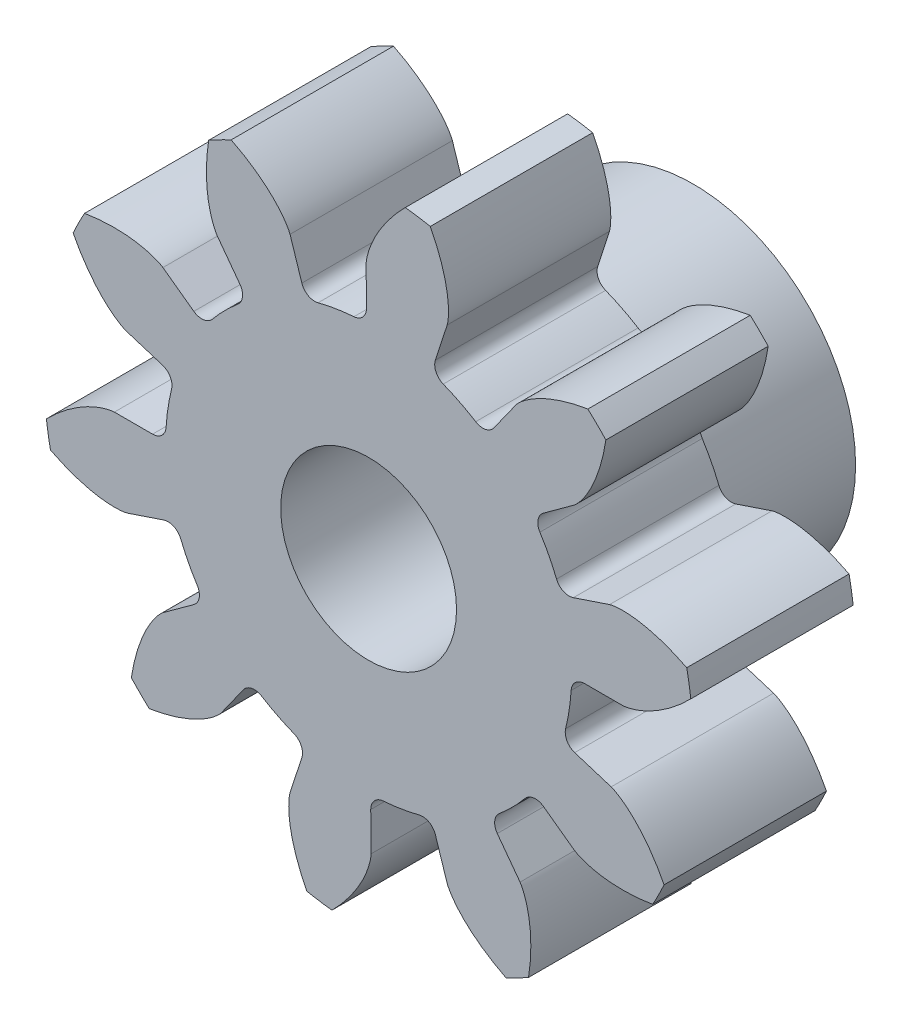
from build123d import *

# Parameters (mm, degrees)
BOSS_EXTRUDE3_DEPTH      = 3
FILLET1_R                = 0.25
CIRPATTERN8_COUNT        = 10
CIRPATTERN8_COPY_1_DEPTH = 3
CIRPATTERN8_COPY_2_DEPTH = 3
CIRPATTERN8_COPY_3_DEPTH = 3
CIRPATTERN8_COPY_4_DEPTH = 3
CIRPATTERN8_COPY_5_DEPTH = 3
CIRPATTERN8_COPY_6_DEPTH = 3
CIRPATTERN8_COPY_7_DEPTH = 3
CIRPATTERN8_COPY_8_DEPTH = 3
CIRPATTERN8_COPY_9_DEPTH = 3
FILLET1_OF_CIRPATTERN8_R = 0.25
SKETCH3_R                = 1.625
CUT_EXTRUDE2_DEPTH       = 9.944202226
SKETCH4_R                = 3
SKETCH4_R_2              = 1.625
BOSS_EXTRUDE4_DEPTH      = 3


with BuildPart() as part:
    # Sketch1 → Boss-Extrude3 (new body)
    with BuildSketch(Plane.XY):
        with BuildLine():
            Line((3.75, 0), (4.698463104, 0))
            add(Edge.make_bspline(
                [(4.698463104, 0), (4.701936693, 7.3507e-05), (4.711671667, 0.000507155), (4.730035453, 0.002224847), (4.759876783, 0.006298442), (4.79766874, 0.013349079), (4.846157716, 0.02458424), (4.902733795, 0.040529055), (4.964229103, 0.060864675), (5.030289125, 0.085989187), (5.095362708, 0.113680418), (5.159425932, 0.143715794), (5.222425493, 0.175792819), (5.297691656, 0.217156604), (5.386434991, 0.270222415), (5.487756287, 0.337177562), (5.599668365, 0.418847249), (5.710232197, 0.508010197), (5.812558898, 0.597496992), (5.886666635, 0.668145407), (5.93326076, 0.714427159), (5.954667219, 0.736164592)],
                knots=[0, 0, 0, 0, 0, 0.005376748, 0.015083688, 0.02853182, 0.046610139, 0.064854849, 0.092110525, 0.119476175, 0.146842495, 0.174208853, 0.201574955, 0.228941013, 0.256307345, 0.307035032, 0.361767351, 0.41649966, 0.471231936, 0.525964281, 0.573449371, 0.573449371, 0.573449371, 0.573449371, 0.573449371], degree=4))
            ThreePointArc((5.954667219, 0.736164592), (5.939189457, 0.852073114), (5.921455736, 0.967657983))
            Line((5.921455736, 0.967657983), (3.700909835, 0.604786239))
            ThreePointArc((3.700909835, 0.604786239), (3.737707311, 0.30338764), (3.75, 0))
        make_face()
        with BuildLine():
            ThreePointArc((-3.700909835, -0.604786239), (0.30338764, -3.737707311), (3.75, 0))
            ThreePointArc((3.75, 0), (3.737707311, 0.30338764), (3.700909835, 0.604786239))
            Line((3.700909835, 0.604786239), (-3.700909835, -0.604786239))
        make_face()
        with BuildLine():
            Line((-3.700909835, -0.604786239), (3.700909835, 0.604786239))
            ThreePointArc((3.700909835, 0.604786239), (-0.604786239, 3.700909835), (-3.700909835, -0.604786239))
        make_face()
    boss_extrude3 = extrude(amount=BOSS_EXTRUDE3_DEPTH)

    # Mirror2: Boss-Extrude3 across plane
    add(boss_extrude3.mirror(Plane(origin=(0, 0, 3), x_dir=(0, 0, 1), z_dir=(0.16127633045793233, -0.9869092892632149, 0))))

    # Fillet1
    fillet1_edges = [part.edges().sort_by_distance(p)[0] for p in [
        (3.75, 0, 1.5),
        (3.554924589, 1.193738315, 1.5),
    ]]
    fillet(fillet1_edges, radius=FILLET1_R)

    # CirPattern8: Boss-Extrude3 ×10 about axis
    cirpattern8_axis = Axis((0, 0, 3), (0, 0, -1))
    for i in range(1, CIRPATTERN8_COUNT):
        add(boss_extrude3.rotate(cirpattern8_axis, i * 360 / CIRPATTERN8_COUNT))

    # CirPattern8 copy 1 sketch → CirPattern8 copy 1 (add)
    with BuildSketch(Plane(origin=(0, 0, 0), x_dir=(0.9540416488225903, -0.2996740434403242, 0), z_dir=(0, 0, 1))):
        with BuildLine():
            Line((3.75, 0), (4.698463104, 0))
            add(Edge.make_bspline(
                [(4.698463104, 0), (4.701936693, -7.3507e-05), (4.711671667, -0.000507155), (4.730035453, -0.002224847), (4.759876783, -0.006298442), (4.79766874, -0.013349079), (4.846157716, -0.02458424), (4.902733795, -0.040529055), (4.964229103, -0.060864675), (5.030289125, -0.085989187), (5.095362708, -0.113680418), (5.159425932, -0.143715794), (5.222425493, -0.175792819), (5.297691656, -0.217156604), (5.386434991, -0.270222415), (5.487756287, -0.337177562), (5.599668365, -0.418847249), (5.710232197, -0.508010197), (5.812558898, -0.597496992), (5.886666635, -0.668145407), (5.93326076, -0.714427159), (5.954667219, -0.736164592)],
                knots=[0, 0, 0, 0, 0, 0.005376748, 0.015083688, 0.02853182, 0.046610139, 0.064854849, 0.092110525, 0.119476175, 0.146842495, 0.174208853, 0.201574955, 0.228941013, 0.256307345, 0.307035032, 0.361767351, 0.41649966, 0.471231936, 0.525964281, 0.573449371, 0.573449371, 0.573449371, 0.573449371, 0.573449371], degree=4))
            ThreePointArc((5.954667219, -0.736164592), (5.939189457, -0.852073114), (5.921455736, -0.967657983))
            Line((5.921455736, -0.967657983), (3.700909835, -0.604786239))
            ThreePointArc((3.700909835, -0.604786239), (3.737707311, -0.30338764), (3.75, 0))
        make_face()
        with BuildLine():
            ThreePointArc((-3.700909835, 0.604786239), (0.30338764, 3.737707311), (3.75, 0))
            ThreePointArc((3.75, 0), (3.737707311, -0.30338764), (3.700909835, -0.604786239))
            Line((3.700909835, -0.604786239), (-3.700909835, 0.604786239))
        make_face()
        with BuildLine():
            Line((-3.700909835, 0.604786239), (3.700909835, -0.604786239))
            ThreePointArc((3.700909835, -0.604786239), (-0.604786239, -3.700909835), (-3.700909835, 0.604786239))
        make_face()
    extrude(amount=CIRPATTERN8_COPY_1_DEPTH)

    # CirPattern8 copy 2 sketch → CirPattern8 copy 2 (add)
    with BuildSketch(Plane(origin=(0, 0, 0), x_dir=(0.5956919240098946, -0.8032130051669918, 0), z_dir=(0, 0, 1))):
        with BuildLine():
            Line((3.75, 0), (4.698463104, 0))
            add(Edge.make_bspline(
                [(4.698463104, 0), (4.701936693, -7.3507e-05), (4.711671667, -0.000507155), (4.730035453, -0.002224847), (4.759876783, -0.006298442), (4.79766874, -0.013349079), (4.846157716, -0.02458424), (4.902733795, -0.040529055), (4.964229103, -0.060864675), (5.030289125, -0.085989187), (5.095362708, -0.113680418), (5.159425932, -0.143715794), (5.222425493, -0.175792819), (5.297691656, -0.217156604), (5.386434991, -0.270222415), (5.487756287, -0.337177562), (5.599668365, -0.418847249), (5.710232197, -0.508010197), (5.812558898, -0.597496992), (5.886666635, -0.668145407), (5.93326076, -0.714427159), (5.954667219, -0.736164592)],
                knots=[0, 0, 0, 0, 0, 0.005376748, 0.015083688, 0.02853182, 0.046610139, 0.064854849, 0.092110525, 0.119476175, 0.146842495, 0.174208853, 0.201574955, 0.228941013, 0.256307345, 0.307035032, 0.361767351, 0.41649966, 0.471231936, 0.525964281, 0.573449371, 0.573449371, 0.573449371, 0.573449371, 0.573449371], degree=4))
            ThreePointArc((5.954667219, -0.736164592), (5.939189457, -0.852073114), (5.921455736, -0.967657983))
            Line((5.921455736, -0.967657983), (3.700909835, -0.604786239))
            ThreePointArc((3.700909835, -0.604786239), (3.737707311, -0.30338764), (3.75, 0))
        make_face()
        with BuildLine():
            ThreePointArc((-3.700909835, 0.604786239), (0.30338764, 3.737707311), (3.75, 0))
            ThreePointArc((3.75, 0), (3.737707311, -0.30338764), (3.700909835, -0.604786239))
            Line((3.700909835, -0.604786239), (-3.700909835, 0.604786239))
        make_face()
        with BuildLine():
            Line((-3.700909835, 0.604786239), (3.700909835, -0.604786239))
            ThreePointArc((3.700909835, -0.604786239), (-0.604786239, -3.700909835), (-3.700909835, 0.604786239))
        make_face()
    extrude(amount=CIRPATTERN8_COPY_2_DEPTH)

    # CirPattern8 copy 3 sketch → CirPattern8 copy 3 (add)
    with BuildSketch(Plane(origin=(0, 0, 0), x_dir=(0.009808131049238777, -0.9999518991258135, 0), z_dir=(0, 0, 1))):
        with BuildLine():
            Line((3.75, 0), (4.698463104, 0))
            add(Edge.make_bspline(
                [(4.698463104, 0), (4.701936693, -7.3507e-05), (4.711671667, -0.000507155), (4.730035453, -0.002224847), (4.759876783, -0.006298442), (4.79766874, -0.013349079), (4.846157716, -0.02458424), (4.902733795, -0.040529055), (4.964229103, -0.060864675), (5.030289125, -0.085989187), (5.095362708, -0.113680418), (5.159425932, -0.143715794), (5.222425493, -0.175792819), (5.297691656, -0.217156604), (5.386434991, -0.270222415), (5.487756287, -0.337177562), (5.599668365, -0.418847249), (5.710232197, -0.508010197), (5.812558898, -0.597496992), (5.886666635, -0.668145407), (5.93326076, -0.714427159), (5.954667219, -0.736164592)],
                knots=[0, 0, 0, 0, 0, 0.005376748, 0.015083688, 0.02853182, 0.046610139, 0.064854849, 0.092110525, 0.119476175, 0.146842495, 0.174208853, 0.201574955, 0.228941013, 0.256307345, 0.307035032, 0.361767351, 0.41649966, 0.471231936, 0.525964281, 0.573449371, 0.573449371, 0.573449371, 0.573449371, 0.573449371], degree=4))
            ThreePointArc((5.954667219, -0.736164592), (5.939189457, -0.852073114), (5.921455736, -0.967657983))
            Line((5.921455736, -0.967657983), (3.700909835, -0.604786239))
            ThreePointArc((3.700909835, -0.604786239), (3.737707311, -0.30338764), (3.75, 0))
        make_face()
        with BuildLine():
            ThreePointArc((-3.700909835, 0.604786239), (0.30338764, 3.737707311), (3.75, 0))
            ThreePointArc((3.75, 0), (3.737707311, -0.30338764), (3.700909835, -0.604786239))
            Line((3.700909835, -0.604786239), (-3.700909835, 0.604786239))
        make_face()
        with BuildLine():
            Line((-3.700909835, 0.604786239), (3.700909835, -0.604786239))
            ThreePointArc((3.700909835, -0.604786239), (-0.604786239, -3.700909835), (-3.700909835, 0.604786239))
        make_face()
    extrude(amount=CIRPATTERN8_COPY_3_DEPTH)

    # CirPattern8 copy 4 sketch → CirPattern8 copy 4 (add)
    with BuildSketch(Plane(origin=(0, 0, 0), x_dir=(-0.5798220346061131, -0.8147431547335806, 0), z_dir=(0, 0, 1))):
        with BuildLine():
            Line((3.75, 0), (4.698463104, 0))
            add(Edge.make_bspline(
                [(4.698463104, 0), (4.701936693, -7.3507e-05), (4.711671667, -0.000507155), (4.730035453, -0.002224847), (4.759876783, -0.006298442), (4.79766874, -0.013349079), (4.846157716, -0.02458424), (4.902733795, -0.040529055), (4.964229103, -0.060864675), (5.030289125, -0.085989187), (5.095362708, -0.113680418), (5.159425932, -0.143715794), (5.222425493, -0.175792819), (5.297691656, -0.217156604), (5.386434991, -0.270222415), (5.487756287, -0.337177562), (5.599668365, -0.418847249), (5.710232197, -0.508010197), (5.812558898, -0.597496992), (5.886666635, -0.668145407), (5.93326076, -0.714427159), (5.954667219, -0.736164592)],
                knots=[0, 0, 0, 0, 0, 0.005376748, 0.015083688, 0.02853182, 0.046610139, 0.064854849, 0.092110525, 0.119476175, 0.146842495, 0.174208853, 0.201574955, 0.228941013, 0.256307345, 0.307035032, 0.361767351, 0.41649966, 0.471231936, 0.525964281, 0.573449371, 0.573449371, 0.573449371, 0.573449371, 0.573449371], degree=4))
            ThreePointArc((5.954667219, -0.736164592), (5.939189457, -0.852073114), (5.921455736, -0.967657983))
            Line((5.921455736, -0.967657983), (3.700909835, -0.604786239))
            ThreePointArc((3.700909835, -0.604786239), (3.737707311, -0.30338764), (3.75, 0))
        make_face()
        with BuildLine():
            ThreePointArc((-3.700909835, 0.604786239), (0.30338764, 3.737707311), (3.75, 0))
            ThreePointArc((3.75, 0), (3.737707311, -0.30338764), (3.700909835, -0.604786239))
            Line((3.700909835, -0.604786239), (-3.700909835, 0.604786239))
        make_face()
        with BuildLine():
            Line((-3.700909835, 0.604786239), (3.700909835, -0.604786239))
            ThreePointArc((3.700909835, -0.604786239), (-0.604786239, -3.700909835), (-3.700909835, 0.604786239))
        make_face()
    extrude(amount=CIRPATTERN8_COPY_4_DEPTH)

    # CirPattern8 copy 5 sketch → CirPattern8 copy 5 (add)
    with BuildSketch(Plane(origin=(0, 0, 0), x_dir=(-0.9479798904680476, -0.31833021733443484, 0), z_dir=(0, 0, 1))):
        with BuildLine():
            Line((3.75, 0), (4.698463104, 0))
            add(Edge.make_bspline(
                [(4.698463104, 0), (4.701936693, -7.3507e-05), (4.711671667, -0.000507155), (4.730035453, -0.002224847), (4.759876783, -0.006298442), (4.79766874, -0.013349079), (4.846157716, -0.02458424), (4.902733795, -0.040529055), (4.964229103, -0.060864675), (5.030289125, -0.085989187), (5.095362708, -0.113680418), (5.159425932, -0.143715794), (5.222425493, -0.175792819), (5.297691656, -0.217156604), (5.386434991, -0.270222415), (5.487756287, -0.337177562), (5.599668365, -0.418847249), (5.710232197, -0.508010197), (5.812558898, -0.597496992), (5.886666635, -0.668145407), (5.93326076, -0.714427159), (5.954667219, -0.736164592)],
                knots=[0, 0, 0, 0, 0, 0.005376748, 0.015083688, 0.02853182, 0.046610139, 0.064854849, 0.092110525, 0.119476175, 0.146842495, 0.174208853, 0.201574955, 0.228941013, 0.256307345, 0.307035032, 0.361767351, 0.41649966, 0.471231936, 0.525964281, 0.573449371, 0.573449371, 0.573449371, 0.573449371, 0.573449371], degree=4))
            ThreePointArc((5.954667219, -0.736164592), (5.939189457, -0.852073114), (5.921455736, -0.967657983))
            Line((5.921455736, -0.967657983), (3.700909835, -0.604786239))
            ThreePointArc((3.700909835, -0.604786239), (3.737707311, -0.30338764), (3.75, 0))
        make_face()
        with BuildLine():
            ThreePointArc((-3.700909835, 0.604786239), (0.30338764, 3.737707311), (3.75, 0))
            ThreePointArc((3.75, 0), (3.737707311, -0.30338764), (3.700909835, -0.604786239))
            Line((3.700909835, -0.604786239), (-3.700909835, 0.604786239))
        make_face()
        with BuildLine():
            Line((-3.700909835, 0.604786239), (3.700909835, -0.604786239))
            ThreePointArc((3.700909835, -0.604786239), (-0.604786239, -3.700909835), (-3.700909835, 0.604786239))
        make_face()
    extrude(amount=CIRPATTERN8_COPY_5_DEPTH)

    # CirPattern8 copy 6 sketch → CirPattern8 copy 6 (add)
    with BuildSketch(Plane(origin=(0, 0, 0), x_dir=(-0.9540416488225905, 0.2996740434403241, 0), z_dir=(0, 0, 1))):
        with BuildLine():
            Line((3.75, 0), (4.698463104, 0))
            add(Edge.make_bspline(
                [(4.698463104, 0), (4.701936693, -7.3507e-05), (4.711671667, -0.000507155), (4.730035453, -0.002224847), (4.759876783, -0.006298442), (4.79766874, -0.013349079), (4.846157716, -0.02458424), (4.902733795, -0.040529055), (4.964229103, -0.060864675), (5.030289125, -0.085989187), (5.095362708, -0.113680418), (5.159425932, -0.143715794), (5.222425493, -0.175792819), (5.297691656, -0.217156604), (5.386434991, -0.270222415), (5.487756287, -0.337177562), (5.599668365, -0.418847249), (5.710232197, -0.508010197), (5.812558898, -0.597496992), (5.886666635, -0.668145407), (5.93326076, -0.714427159), (5.954667219, -0.736164592)],
                knots=[0, 0, 0, 0, 0, 0.005376748, 0.015083688, 0.02853182, 0.046610139, 0.064854849, 0.092110525, 0.119476175, 0.146842495, 0.174208853, 0.201574955, 0.228941013, 0.256307345, 0.307035032, 0.361767351, 0.41649966, 0.471231936, 0.525964281, 0.573449371, 0.573449371, 0.573449371, 0.573449371, 0.573449371], degree=4))
            ThreePointArc((5.954667219, -0.736164592), (5.939189457, -0.852073114), (5.921455736, -0.967657983))
            Line((5.921455736, -0.967657983), (3.700909835, -0.604786239))
            ThreePointArc((3.700909835, -0.604786239), (3.737707311, -0.30338764), (3.75, 0))
        make_face()
        with BuildLine():
            ThreePointArc((-3.700909835, 0.604786239), (0.30338764, 3.737707311), (3.75, 0))
            ThreePointArc((3.75, 0), (3.737707311, -0.30338764), (3.700909835, -0.604786239))
            Line((3.700909835, -0.604786239), (-3.700909835, 0.604786239))
        make_face()
        with BuildLine():
            Line((-3.700909835, 0.604786239), (3.700909835, -0.604786239))
            ThreePointArc((3.700909835, -0.604786239), (-0.604786239, -3.700909835), (-3.700909835, 0.604786239))
        make_face()
    extrude(amount=CIRPATTERN8_COPY_6_DEPTH)

    # CirPattern8 copy 7 sketch → CirPattern8 copy 7 (add)
    with BuildSketch(Plane(origin=(0, 0, 0), x_dir=(-0.5956919240098947, 0.8032130051669918, 0), z_dir=(0, 0, 1))):
        with BuildLine():
            Line((3.75, 0), (4.698463104, 0))
            add(Edge.make_bspline(
                [(4.698463104, 0), (4.701936693, -7.3507e-05), (4.711671667, -0.000507155), (4.730035453, -0.002224847), (4.759876783, -0.006298442), (4.79766874, -0.013349079), (4.846157716, -0.02458424), (4.902733795, -0.040529055), (4.964229103, -0.060864675), (5.030289125, -0.085989187), (5.095362708, -0.113680418), (5.159425932, -0.143715794), (5.222425493, -0.175792819), (5.297691656, -0.217156604), (5.386434991, -0.270222415), (5.487756287, -0.337177562), (5.599668365, -0.418847249), (5.710232197, -0.508010197), (5.812558898, -0.597496992), (5.886666635, -0.668145407), (5.93326076, -0.714427159), (5.954667219, -0.736164592)],
                knots=[0, 0, 0, 0, 0, 0.005376748, 0.015083688, 0.02853182, 0.046610139, 0.064854849, 0.092110525, 0.119476175, 0.146842495, 0.174208853, 0.201574955, 0.228941013, 0.256307345, 0.307035032, 0.361767351, 0.41649966, 0.471231936, 0.525964281, 0.573449371, 0.573449371, 0.573449371, 0.573449371, 0.573449371], degree=4))
            ThreePointArc((5.954667219, -0.736164592), (5.939189457, -0.852073114), (5.921455736, -0.967657983))
            Line((5.921455736, -0.967657983), (3.700909835, -0.604786239))
            ThreePointArc((3.700909835, -0.604786239), (3.737707311, -0.30338764), (3.75, 0))
        make_face()
        with BuildLine():
            ThreePointArc((-3.700909835, 0.604786239), (0.30338764, 3.737707311), (3.75, 0))
            ThreePointArc((3.75, 0), (3.737707311, -0.30338764), (3.700909835, -0.604786239))
            Line((3.700909835, -0.604786239), (-3.700909835, 0.604786239))
        make_face()
        with BuildLine():
            Line((-3.700909835, 0.604786239), (3.700909835, -0.604786239))
            ThreePointArc((3.700909835, -0.604786239), (-0.604786239, -3.700909835), (-3.700909835, 0.604786239))
        make_face()
    extrude(amount=CIRPATTERN8_COPY_7_DEPTH)

    # CirPattern8 copy 8 sketch → CirPattern8 copy 8 (add)
    with BuildSketch(Plane(origin=(0, 0, 0), x_dir=(-0.009808131049238888, 0.9999518991258135, 0), z_dir=(0, 0, 1))):
        with BuildLine():
            Line((3.75, 0), (4.698463104, 0))
            add(Edge.make_bspline(
                [(4.698463104, 0), (4.701936693, -7.3507e-05), (4.711671667, -0.000507155), (4.730035453, -0.002224847), (4.759876783, -0.006298442), (4.79766874, -0.013349079), (4.846157716, -0.02458424), (4.902733795, -0.040529055), (4.964229103, -0.060864675), (5.030289125, -0.085989187), (5.095362708, -0.113680418), (5.159425932, -0.143715794), (5.222425493, -0.175792819), (5.297691656, -0.217156604), (5.386434991, -0.270222415), (5.487756287, -0.337177562), (5.599668365, -0.418847249), (5.710232197, -0.508010197), (5.812558898, -0.597496992), (5.886666635, -0.668145407), (5.93326076, -0.714427159), (5.954667219, -0.736164592)],
                knots=[0, 0, 0, 0, 0, 0.005376748, 0.015083688, 0.02853182, 0.046610139, 0.064854849, 0.092110525, 0.119476175, 0.146842495, 0.174208853, 0.201574955, 0.228941013, 0.256307345, 0.307035032, 0.361767351, 0.41649966, 0.471231936, 0.525964281, 0.573449371, 0.573449371, 0.573449371, 0.573449371, 0.573449371], degree=4))
            ThreePointArc((5.954667219, -0.736164592), (5.939189457, -0.852073114), (5.921455736, -0.967657983))
            Line((5.921455736, -0.967657983), (3.700909835, -0.604786239))
            ThreePointArc((3.700909835, -0.604786239), (3.737707311, -0.30338764), (3.75, 0))
        make_face()
        with BuildLine():
            ThreePointArc((-3.700909835, 0.604786239), (0.30338764, 3.737707311), (3.75, 0))
            ThreePointArc((3.75, 0), (3.737707311, -0.30338764), (3.700909835, -0.604786239))
            Line((3.700909835, -0.604786239), (-3.700909835, 0.604786239))
        make_face()
        with BuildLine():
            Line((-3.700909835, 0.604786239), (3.700909835, -0.604786239))
            ThreePointArc((3.700909835, -0.604786239), (-0.604786239, -3.700909835), (-3.700909835, 0.604786239))
        make_face()
    extrude(amount=CIRPATTERN8_COPY_8_DEPTH)

    # CirPattern8 copy 9 sketch → CirPattern8 copy 9 (add)
    with BuildSketch(Plane(origin=(0, 0, 0), x_dir=(0.5798220346061131, 0.8147431547335808, 0), z_dir=(0, 0, 1))):
        with BuildLine():
            Line((3.75, 0), (4.698463104, 0))
            add(Edge.make_bspline(
                [(4.698463104, 0), (4.701936693, -7.3507e-05), (4.711671667, -0.000507155), (4.730035453, -0.002224847), (4.759876783, -0.006298442), (4.79766874, -0.013349079), (4.846157716, -0.02458424), (4.902733795, -0.040529055), (4.964229103, -0.060864675), (5.030289125, -0.085989187), (5.095362708, -0.113680418), (5.159425932, -0.143715794), (5.222425493, -0.175792819), (5.297691656, -0.217156604), (5.386434991, -0.270222415), (5.487756287, -0.337177562), (5.599668365, -0.418847249), (5.710232197, -0.508010197), (5.812558898, -0.597496992), (5.886666635, -0.668145407), (5.93326076, -0.714427159), (5.954667219, -0.736164592)],
                knots=[0, 0, 0, 0, 0, 0.005376748, 0.015083688, 0.02853182, 0.046610139, 0.064854849, 0.092110525, 0.119476175, 0.146842495, 0.174208853, 0.201574955, 0.228941013, 0.256307345, 0.307035032, 0.361767351, 0.41649966, 0.471231936, 0.525964281, 0.573449371, 0.573449371, 0.573449371, 0.573449371, 0.573449371], degree=4))
            ThreePointArc((5.954667219, -0.736164592), (5.939189457, -0.852073114), (5.921455736, -0.967657983))
            Line((5.921455736, -0.967657983), (3.700909835, -0.604786239))
            ThreePointArc((3.700909835, -0.604786239), (3.737707311, -0.30338764), (3.75, 0))
        make_face()
        with BuildLine():
            ThreePointArc((-3.700909835, 0.604786239), (0.30338764, 3.737707311), (3.75, 0))
            ThreePointArc((3.75, 0), (3.737707311, -0.30338764), (3.700909835, -0.604786239))
            Line((3.700909835, -0.604786239), (-3.700909835, 0.604786239))
        make_face()
        with BuildLine():
            Line((-3.700909835, 0.604786239), (3.700909835, -0.604786239))
            ThreePointArc((3.700909835, -0.604786239), (-0.604786239, -3.700909835), (-3.700909835, 0.604786239))
        make_face()
    extrude(amount=CIRPATTERN8_COPY_9_DEPTH)

    # Fillet1 of CirPattern8
    fillet1_of_cirpattern8_edges = [part.edges().sort_by_distance(p)[0] for p in [
        (3.033813729, -2.204194696, 1.5),
        (3.577656183, -1.123777663, 1.5),
        (1.158813729, -3.566461936, 1.5),
        (2.233844715, -3.012048769, 1.5),
        (-1.158813729, -3.566461936, 1.5),
        (0.036780491, -3.749819622, 1.5),
        (-3.033813729, -2.204194696, 1.5),
        (-2.17433263, -3.05528683, 1.5),
        (-3.75, 0, 1.5),
        (-3.554924589, -1.193738315, 1.5),
        (-3.033813729, 2.204194696, 1.5),
        (-3.577656183, 1.123777663, 1.5),
        (-1.158813729, 3.566461936, 1.5),
        (-2.233844715, 3.012048769, 1.5),
        (1.158813729, 3.566461936, 1.5),
        (-0.036780491, 3.749819622, 1.5),
        (3.033813729, 2.204194696, 1.5),
        (2.17433263, 3.05528683, 1.5),
    ]]
    fillet(fillet1_of_cirpattern8_edges, radius=FILLET1_OF_CIRPATTERN8_R)

    # Sketch3 → Cut-Extrude2 (cut, through all)
    with BuildSketch(Plane.XY.offset(3)):
        Circle(SKETCH3_R)
    extrude(amount=-CUT_EXTRUDE2_DEPTH, mode=Mode.SUBTRACT)

    # Sketch4 → Boss-Extrude4 (add)
    with BuildSketch(Plane(origin=(0, 0, 0), x_dir=(-1, 0, 0), z_dir=(0, 0, -1))):
        with Locations(Location((0, 0, 0), (0, 0, 180))):
            Circle(SKETCH4_R)
        with Locations(Location((0, 0, 0), (0, 0, 180))):
            Circle(SKETCH4_R_2, mode=Mode.SUBTRACT)
    extrude(amount=BOSS_EXTRUDE4_DEPTH)


solid = part.part
